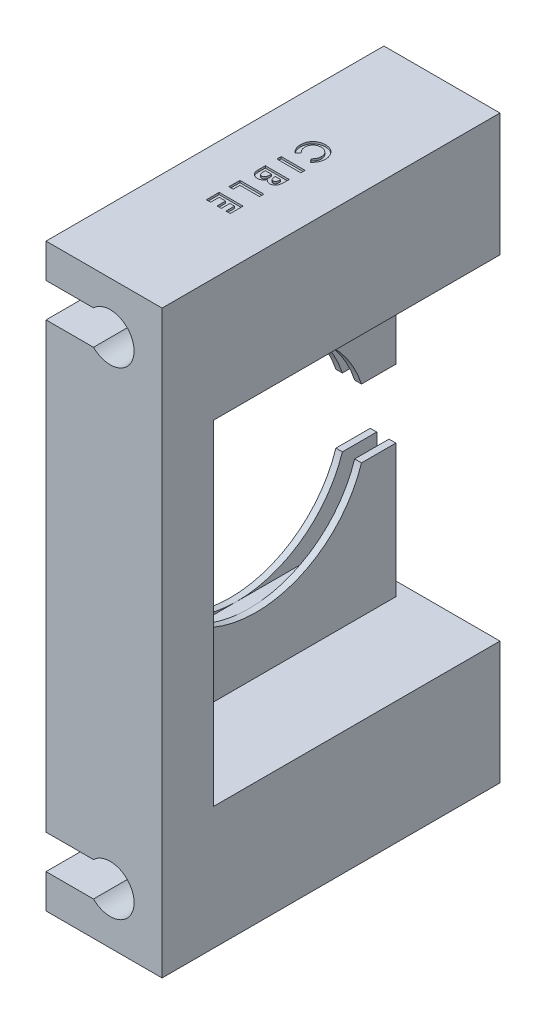
from build123d import *

# Parameters (mm, degrees)
ESQUISSE1_W             = 17
ESQUISSE1_H             = 85
BOSS_EXTRU_1_DEPTH      = 49.5
ESQUISSE2_W             = 1.8
ESQUISSE2_H             = 32.5
ENL_V_MAT_EXTRU_1_DEPTH = 38.5
ESQUISSE3_W             = 17
ESQUISSE3_H             = 49
ENL_V_MAT_EXTRU_2_DEPTH = 2
ESQUISSE4_R             = 16.25
ENL_V_MAT_EXTRU_3_DEPTH = 18
ESQUISSE5_W             = 5.038353904
ESQUISSE5_H             = 10
ENL_V_MAT_EXTRU_4_DEPTH = 18
ENL_V_MAT_EXTRU_5_DEPTH = 50.5
ESQUISSE7_W             = 40
ESQUISSE7_H             = 49
ENL_V_MAT_EXTRU_7_DEPTH = 13.25
ESQUISSE8_W             = 3.5
ESQUISSE8_H             = 0.628205128
ENL_V_MAT_EXTRU_8_DEPTH = 0.3


with BuildPart() as part:
    # Esquisse1 → Boss.-Extru.1 (new body)
    with BuildSketch(Plane.XY):
        Rectangle(ESQUISSE1_W, ESQUISSE1_H)
    extrude(amount=BOSS_EXTRU_1_DEPTH)

    # Esquisse2 → Enlèv. mat.-Extru.1 (cut)
    with BuildSketch(Plane(origin=(0, 0, 0), x_dir=(-1, 0, 0), z_dir=(0, 0, -1))):
        with Locations((6.65, 0)):
            Rectangle(ESQUISSE2_W, ESQUISSE2_H)
    extrude(amount=-ENL_V_MAT_EXTRU_1_DEPTH, mode=Mode.SUBTRACT)

    # Esquisse3 → Enlèv. mat.-Extru.2 (cut)
    with BuildSketch(Plane(origin=(0, 0, 0), x_dir=(-1, 0, 0), z_dir=(0, 0, -1))):
        Rectangle(ESQUISSE3_W, ESQUISSE3_H)
    extrude(amount=-ENL_V_MAT_EXTRU_2_DEPTH, mode=Mode.SUBTRACT)

    # Esquisse4 → Enlèv. mat.-Extru.3 (cut, through all)
    with BuildSketch(Plane.ZY.offset(8.5)):
        with Locations((22.5, 0)):
            Circle(ESQUISSE4_R)
    extrude(amount=-ENL_V_MAT_EXTRU_3_DEPTH, mode=Mode.SUBTRACT)

    # Esquisse5 → Enlèv. mat.-Extru.4 (cut, through all)
    with BuildSketch(Plane.ZY.offset(8.5)):
        with Locations((4.519176952, 0)):
            Rectangle(ESQUISSE5_W, ESQUISSE5_H)
    extrude(amount=-ENL_V_MAT_EXTRU_4_DEPTH, mode=Mode.SUBTRACT)

    # Esquisse6 → Enlèv. mat.-Extru.5 (cut, through all)
    with BuildSketch(Plane(origin=(0, 0, 0), x_dir=(-1, 0, 0), z_dir=(0, 0, -1))):
        with BuildLine():
            Line((8.5, -32.5), (1.55, -32.5))
            ThreePointArc((1.55, -32.5), (-4.399489743, -35), (1.55, -37.5))
            Line((1.55, -37.5), (8.5, -37.5))
            Line((8.5, -37.5), (8.5, -32.5))
        make_face()
        with BuildLine():
            Line((8.5, 32.5), (8.5, 37.5))
            Line((8.5, 37.5), (1.55, 37.5))
            ThreePointArc((1.55, 37.5), (-4.399489743, 35), (1.55, 32.5))
            Line((1.55, 32.5), (8.5, 32.5))
        make_face()
    extrude(amount=-ENL_V_MAT_EXTRU_5_DEPTH, mode=Mode.SUBTRACT)

    # Esquisse7 → Enlèv. mat.-Extru.7 (cut)
    with BuildSketch(Plane(origin=(8.5, 0, 0), x_dir=(0, 0, -1), z_dir=(1, 0, 0))):
        with Locations((-22, 0)):
            Rectangle(ESQUISSE7_W, ESQUISSE7_H)
    extrude(amount=-ENL_V_MAT_EXTRU_7_DEPTH, mode=Mode.SUBTRACT)

    # Esquisse8 → Enlèv. mat.-Extru.8 (cut)
    with BuildSketch(Plane(origin=(0, 42.5, 0), x_dir=(1, 0, 0), z_dir=(0, 1, 0))):
        with BuildLine():
            Line((0.892828526, -20.123717949), (0.452524038, -19.663080929))
            add(Edge.make_bspline(
                [(0.452524038, -19.663080929), (0.492979524, -19.624047785), (0.572130399, -19.54767971), (0.675863197, -19.424099216), (0.763657071, -19.29672775), (0.836680847, -19.166421817), (0.89238701, -19.031170458), (0.93243686, -18.892753798), (0.957375261, -18.750419386), (0.960143016, -18.654267211), (0.961538462, -18.605789263)],
                knots=[0, 0, 0, 0, 0.000168561, 0.000329789, 0.000483038, 0.000632107, 0.000777024, 0.00092081, 0.001063737, 0.001209074, 0.001209074, 0.001209074, 0.001209074], degree=3))
            add(Edge.make_bspline(
                [(0.961538462, -18.605789263), (0.960417785, -18.565308134), (0.958206253, -18.485423085), (0.941993543, -18.3681309), (0.914423124, -18.255934864), (0.876425979, -18.14845091), (0.82725969, -18.045995317), (0.766962311, -17.948353272), (0.696078413, -17.855765508), (0.614974752, -17.769455056), (0.526362907, -17.690501288), (0.431814281, -17.620740606), (0.331545478, -17.562304845), (0.226571947, -17.514347567), (0.116407818, -17.476990701), (0.00112726, -17.450313205), (-0.11940702, -17.434883654), (-0.201345325, -17.43258069), (-0.242988782, -17.431410256)],
                knots=[0, 0, 0, 0, 0.000121424, 0.000239616, 0.000354399, 0.000467495, 0.000581016, 0.000694652, 0.000811184, 0.000930234, 0.001049421, 0.001166795, 0.001282115, 0.001396947, 0.001512462, 0.001630492, 0.001751372, 0.001876298, 0.001876298, 0.001876298, 0.001876298], degree=3))
            add(Edge.make_bspline(
                [(-0.242988782, -17.431410256), (-0.272217222, -17.431747133), (-0.329827078, -17.432411122), (-0.415045483, -17.439695106), (-0.497737386, -17.451391366), (-0.577731399, -17.468433847), (-0.655337044, -17.489364428), (-0.730533477, -17.515376816), (-0.803275516, -17.546269017), (-0.87342598, -17.581165834), (-0.940175486, -17.620550266), (-1.003539523, -17.664010651), (-1.062711316, -17.711972869), (-1.11971498, -17.762196122), (-1.171146601, -17.818082617), (-1.219988077, -17.877036114), (-1.264578548, -17.940311922), (-1.306127771, -18.006494223), (-1.342217212, -18.076182553), (-1.374908584, -18.147478611), (-1.401458516, -18.221465416), (-1.422860269, -18.297241593), (-1.44105924, -18.374536491), (-1.452264911, -18.454106087), (-1.460750832, -18.535260621), (-1.461274788, -18.590107464), (-1.461538462, -18.617708333)],
                knots=[0, 0, 0, 0, 8.7665e-05, 0.00017279, 0.000256377, 0.000338057, 0.000417997, 0.000497376, 0.00057655, 0.000654938, 0.000732255, 0.00080888, 0.000885199, 0.00096066, 0.001036553, 0.001112769, 0.001190198, 0.001268605, 0.001347008, 0.001425458, 0.001503749, 0.001582528, 0.001661618, 0.001741736, 0.001823431, 0.00190619, 0.00190619, 0.00190619, 0.00190619], degree=3))
            add(Edge.make_bspline(
                [(-1.461538462, -18.617708333), (-1.460182281, -18.664523464), (-1.457517739, -18.756503022), (-1.43674117, -18.891508003), (-1.402355601, -19.02031964), (-1.362156235, -19.123404197), (-1.322355109, -19.204024238), (-1.285026926, -19.264846044), (-1.243990065, -19.328158362), (-1.196715082, -19.392560804), (-1.144125557, -19.458757489), (-1.084997394, -19.525536951), (-1.02129842, -19.594621337), (-0.975834323, -19.639877339), (-0.952524038, -19.663080929)],
                knots=[0, 0, 0, 0, 0.0001404, 0.000275849, 0.000408674, 0.000539654, 0.000607068, 0.00067813, 0.000753582, 0.000833377, 0.00091769, 0.001007126, 0.00110089, 0.00119955, 0.00119955, 0.00119955, 0.00119955], degree=3))
            Line((-0.952524038, -19.663080929), (-1.421574519, -20.109695513))
            add(Edge.make_bspline(
                [(-1.421574519, -20.109695513), (-1.451885022, -20.078300912), (-1.511044642, -20.017025365), (-1.595045762, -19.924592897), (-1.670530181, -19.832276783), (-1.740237307, -19.742307079), (-1.802137589, -19.653210371), (-1.856288708, -19.564994781), (-1.904074721, -19.478663562), (-1.944639408, -19.392407794), (-1.979302868, -19.305542773), (-2.008536317, -19.216205464), (-2.034055114, -19.12435318), (-2.054137091, -19.029225198), (-2.07048521, -18.931245968), (-2.081287688, -18.83010065), (-2.088778526, -18.726261826), (-2.089419276, -18.656050173), (-2.08974359, -18.620512821)],
                knots=[0, 0, 0, 0, 0.000130917, 0.000255521, 0.000374557, 0.000488566, 0.000596896, 0.00069983, 0.000798983, 0.000892761, 0.00098559, 0.001079375, 0.001174627, 0.001271438, 0.001370911, 0.001472494, 0.001576496, 0.001683088, 0.001683088, 0.001683088, 0.001683088], degree=3))
            add(Edge.make_bspline(
                [(-2.08974359, -18.620512821), (-2.088076654, -18.555237623), (-2.084814924, -18.427512205), (-2.06073091, -18.24031589), (-2.020087909, -18.062336882), (-1.963388381, -17.893255379), (-1.889764346, -17.733588841), (-1.80043004, -17.582836552), (-1.694537582, -17.441249559), (-1.573664673, -17.310046206), (-1.440142608, -17.191403716), (-1.296831478, -17.086418947), (-1.14270213, -16.999957499), (-0.981056111, -16.926599404), (-0.809366273, -16.871628655), (-0.62918403, -16.831614795), (-0.439736159, -16.807266569), (-0.310369077, -16.804576885), (-0.244391026, -16.803205128)],
                knots=[0, 0, 0, 0, 0.000195794, 0.000383114, 0.000565099, 0.000742694, 0.00091712, 0.001091592, 0.001267434, 0.00144656, 0.001625835, 0.00180254, 0.001978381, 0.00215507, 0.00233422, 0.002518103, 0.002708205, 0.002906072, 0.002906072, 0.002906072, 0.002906072], degree=3))
            add(Edge.make_bspline(
                [(-0.244391026, -16.803205128), (-0.201363592, -16.803810032), (-0.116093736, -16.805008804), (0.009629506, -16.816608067), (0.131830903, -16.834852162), (0.250134535, -16.859939659), (0.365199642, -16.892303656), (0.47626848, -16.932079243), (0.583801292, -16.97944215), (0.687110508, -17.03418337), (0.786768715, -17.09478929), (0.881038016, -17.162777966), (0.970932337, -17.236066303), (1.055281654, -17.316461103), (1.13441781, -17.402867616), (1.209311214, -17.495047813), (1.278558749, -17.594115662), (1.342500577, -17.698646602), (1.400908825, -17.806999432), (1.451128993, -17.91841644), (1.494305026, -18.031872966), (1.529436028, -18.147320375), (1.555863311, -18.265293674), (1.575825508, -18.384840995), (1.586993704, -18.506952822), (1.588821121, -18.588941295), (1.58974359, -18.630328526)],
                knots=[0, 0, 0, 0, 0.000129054, 0.000255754, 0.00037841, 0.000499558, 0.000618304, 0.00073673, 0.000853194, 0.000970489, 0.001087248, 0.001202821, 0.001318896, 0.001434944, 0.00155205, 0.001670199, 0.001790992, 0.001914365, 0.002037639, 0.002160014, 0.002280726, 0.002401606, 0.002521686, 0.002643174, 0.002764986, 0.002889156, 0.002889156, 0.002889156, 0.002889156], degree=3))
            add(Edge.make_bspline(
                [(1.58974359, -18.630328526), (1.589214692, -18.665636008), (1.588162395, -18.735883873), (1.579390354, -18.840494732), (1.565613953, -18.944268962), (1.544828298, -19.04683502), (1.520153099, -19.148926563), (1.487844329, -19.249201994), (1.451830117, -19.349243212), (1.408782479, -19.447481218), (1.361792095, -19.54405314), (1.308479797, -19.636696627), (1.252126365, -19.726967155), (1.189396556, -19.812864383), (1.122565697, -19.895997352), (1.051321984, -19.975931352), (0.974477576, -20.051964915), (0.920182466, -20.099679357), (0.892828526, -20.123717949)],
                knots=[0, 0, 0, 0, 0.000105907, 0.000210712, 0.000314726, 0.000419778, 0.000524527, 0.000629634, 0.000735659, 0.000843372, 0.000951235, 0.001057679, 0.001163882, 0.001270328, 0.001376541, 0.001483792, 0.001591374, 0.001700605, 0.001700605, 0.001700605, 0.001700605], degree=3))
        make_face()
        with Locations((-0.25, -21.86474359)):
            Rectangle(ESQUISSE8_W, ESQUISSE8_H)
        with BuildLine():
            Line((-2, -23.875), (1.5, -23.875))
            Line((1.5, -23.875), (1.5, -24.435897436))
            add(Edge.make_bspline(
                [(1.5, -24.435897436), (1.50000536, -24.475163834), (1.500015733, -24.551143568), (1.496154483, -24.660761363), (1.491225903, -24.762193758), (1.485526787, -24.85556454), (1.476068427, -24.940839142), (1.465889445, -25.018076292), (1.453695322, -25.086989929), (1.442749743, -25.129594966), (1.43760016, -25.149639423)],
                knots=[0, 0, 0, 0, 0.000117791, 0.000227922, 0.000329003, 0.000422466, 0.000508487, 0.000586324, 0.000656183, 0.000718251, 0.000718251, 0.000718251, 0.000718251], degree=3))
            add(Edge.make_bspline(
                [(1.43760016, -25.149639423), (1.430337123, -25.175959882), (1.416084713, -25.227609071), (1.387301352, -25.301587189), (1.355306611, -25.371765767), (1.318806577, -25.438059055), (1.277360679, -25.500060219), (1.230639665, -25.557532774), (1.180520114, -25.611719465), (1.125600708, -25.660684468), (1.067581371, -25.704974532), (1.006416421, -25.743331613), (0.943340586, -25.777069799), (0.876600899, -25.802456653), (0.808162146, -25.823993438), (0.736710385, -25.838366162), (0.662892968, -25.848019711), (0.612645625, -25.848908045), (0.587139423, -25.849358974)],
                knots=[0, 0, 0, 0, 8.1863e-05, 0.000160642, 0.000237816, 0.000313134, 0.000387417, 0.000461218, 0.000535129, 0.000608609, 0.000681668, 0.000753832, 0.000825019, 0.000895846, 0.000967704, 0.001040031, 0.001114211, 0.001190685, 0.001190685, 0.001190685, 0.001190685], degree=3))
            add(Edge.make_bspline(
                [(0.587139423, -25.849358974), (0.554354632, -25.848261293), (0.489783084, -25.846099344), (0.395351674, -25.829603838), (0.305504717, -25.802713305), (0.219386136, -25.765637244), (0.137982822, -25.714402776), (0.05874724, -25.651645242), (-0.016938219, -25.574468457), (-0.063321571, -25.516299082), (-0.087339744, -25.486177885)],
                knots=[0, 0, 0, 0, 9.8317e-05, 0.000193641, 0.000286584, 0.000379201, 0.000473959, 0.000574259, 0.000681842, 0.000797376, 0.000797376, 0.000797376, 0.000797376], degree=3))
            add(Edge.make_bspline(
                [(-0.087339744, -25.486177885), (-0.099935684, -25.510855901), (-0.124632838, -25.559242664), (-0.165250576, -25.627916477), (-0.208365929, -25.691580499), (-0.253606804, -25.7502883), (-0.301303518, -25.803834841), (-0.35168152, -25.851871997), (-0.403869708, -25.895401706), (-0.458931482, -25.933385952), (-0.516205896, -25.966502468), (-0.575790266, -25.995581352), (-0.638531531, -26.018871261), (-0.703099558, -26.039767412), (-0.770453715, -26.055080271), (-0.840358974, -26.065137281), (-0.912626075, -26.072815075), (-0.961850742, -26.073413619), (-0.986879006, -26.073717949)],
                knots=[0, 0, 0, 0, 8.3106e-05, 0.000162948, 0.000239177, 0.000313644, 0.000385145, 0.000454073, 0.000522298, 0.000588812, 0.000654471, 0.000720637, 0.000787435, 0.000855067, 0.00092412, 0.000994323, 0.001066878, 0.001141928, 0.001141928, 0.001141928, 0.001141928], degree=3))
            add(Edge.make_bspline(
                [(-0.986879006, -26.073717949), (-1.034705293, -26.071843399), (-1.129137841, -26.068142118), (-1.267275543, -26.038265609), (-1.399022656, -25.990319954), (-1.522437164, -25.923735188), (-1.634779483, -25.842199433), (-1.733196402, -25.748344324), (-1.816229786, -25.643304868), (-1.872772226, -25.546751859), (-1.910535169, -25.462838179), (-1.933565918, -25.393021638), (-1.955343301, -25.31822054), (-1.970483547, -25.23707688), (-1.984380185, -25.150910525), (-1.992951768, -25.058863409), (-1.998763142, -24.961112785), (-1.999579379, -24.893973214), (-2, -24.859375)],
                knots=[0, 0, 0, 0, 0.000143365, 0.000283073, 0.000421924, 0.000562767, 0.000702306, 0.000837188, 0.000969462, 0.001102698, 0.00117175, 0.001245141, 0.001323054, 0.001405279, 0.00149254, 0.001584838, 0.001682455, 0.001786243, 0.001786243, 0.001786243, 0.001786243], degree=3))
            Line((-2, -24.859375), (-2, -23.875))
        make_face()
        with BuildLine():
            Line((0.871794872, -24.503205128), (0.108974359, -24.503205128))
            Line((0.108974359, -24.503205128), (0.108974359, -24.670072115))
            add(Edge.make_bspline(
                [(0.108974359, -24.670072115), (0.109171225, -24.69275112), (0.109551262, -24.736531565), (0.114480491, -24.79976322), (0.122828058, -24.858574885), (0.134722017, -24.912888752), (0.149134515, -24.963022098), (0.167465833, -25.008381174), (0.189337964, -25.049113273), (0.221123447, -25.097105682), (0.269799001, -25.146540738), (0.338508063, -25.190807202), (0.418036323, -25.216750496), (0.47406989, -25.219654342), (0.503004808, -25.221153846)],
                knots=[0, 0, 0, 0, 6.8023e-05, 0.000131315, 0.000190113, 0.000246084, 0.000297996, 0.000346429, 0.000392538, 0.000436486, 0.000518789, 0.000598535, 0.000679684, 0.000766331, 0.000766331, 0.000766331, 0.000766331], degree=3))
            add(Edge.make_bspline(
                [(0.503004808, -25.221153846), (0.530108539, -25.219954393), (0.582512513, -25.217635299), (0.656143792, -25.191495958), (0.721052547, -25.150774604), (0.76613246, -25.103427145), (0.79640828, -25.058268173), (0.816697538, -25.019424821), (0.834315671, -24.976555836), (0.848252757, -24.929319098), (0.858521622, -24.877885277), (0.866104544, -24.822392376), (0.871254183, -24.762716345), (0.871610776, -24.721499194), (0.871794872, -24.700220353)],
                knots=[0, 0, 0, 0, 8.0997e-05, 0.000156604, 0.000231296, 0.000309146, 0.000350566, 0.000394159, 0.00044038, 0.000489404, 0.000541655, 0.000597578, 0.000657375, 0.000721192, 0.000721192, 0.000721192, 0.000721192], degree=3))
            Line((0.871794872, -24.700220353), (0.871794872, -24.503205128))
        make_face(mode=Mode.SUBTRACT)
        with BuildLine():
            Line((-0.474358974, -24.503205128), (-1.371794872, -24.503205128))
            Line((-1.371794872, -24.503205128), (-1.371794872, -24.684094551))
            add(Edge.make_bspline(
                [(-1.371794872, -24.684094551), (-1.371590564, -24.719856621), (-1.371197758, -24.788613661), (-1.366451722, -24.887108), (-1.357897829, -24.976663978), (-1.347218983, -25.057044305), (-1.332750816, -25.128372099), (-1.314356397, -25.190406254), (-1.294119331, -25.24399749), (-1.269124153, -25.28882447), (-1.240035963, -25.325445544), (-1.210307135, -25.358492224), (-1.176012123, -25.385436428), (-1.138623117, -25.406755185), (-1.099068886, -25.425206531), (-1.055804853, -25.43633508), (-1.01011326, -25.444807967), (-0.978509373, -25.445274253), (-0.962339744, -25.445512821)],
                knots=[0, 0, 0, 0, 0.000107281, 0.000206261, 0.0002957, 0.000377105, 0.000449433, 0.000513769, 0.000571055, 0.000620973, 0.00066697, 0.000711118, 0.000754041, 0.00079709, 0.000840088, 0.000884486, 0.000930707, 0.00097913, 0.00097913, 0.00097913, 0.00097913], degree=3))
            add(Edge.make_bspline(
                [(-0.962339744, -25.445512821), (-0.943849461, -25.444986766), (-0.907835364, -25.443962154), (-0.855197875, -25.435592465), (-0.806053654, -25.42038626), (-0.759163202, -25.401219383), (-0.716142559, -25.374600564), (-0.675874813, -25.342874029), (-0.638632329, -25.305320557), (-0.603779423, -25.262214531), (-0.572726868, -25.211923053), (-0.546409048, -25.154099336), (-0.52387688, -25.089077516), (-0.506161516, -25.01646023), (-0.491072633, -24.936491106), (-0.482075762, -24.848548086), (-0.475379896, -24.753375202), (-0.474707014, -24.687380261), (-0.474358974, -24.653245192)],
                knots=[0, 0, 0, 0, 5.546e-05, 0.00010802, 0.00015926, 0.000209526, 0.000259547, 0.000310464, 0.000363015, 0.000417873, 0.000476437, 0.000539802, 0.000608096, 0.000682577, 0.000763849, 0.000852038, 0.000947599, 0.001049984, 0.001049984, 0.001049984, 0.001049984], degree=3))
            Line((-0.474358974, -24.653245192), (-0.474358974, -24.503205128))
        make_face(mode=Mode.SUBTRACT)
        Polygon((1.5, -27.590384615), (1.5, -28.218589744), (-1.371794872, -28.218589744), (-1.371794872, -29.205769231), (-2, -29.205769231), (-2, -27.590384615), align=None)
        Polygon((1.5, -30.632692308), (1.5, -32.517307692), (0.871794872, -32.517307692), (0.871794872, -31.260897436), (0.198717949, -31.260897436), (0.198717949, -32.517307692), (-0.429487179, -32.517307692), (-0.429487179, -31.260897436), (-1.371794872, -31.260897436), (-1.371794872, -32.517307692), (-2, -32.517307692), (-2, -30.632692308), align=None)
    extrude(amount=-ENL_V_MAT_EXTRU_8_DEPTH, mode=Mode.SUBTRACT)


solid = part.part
